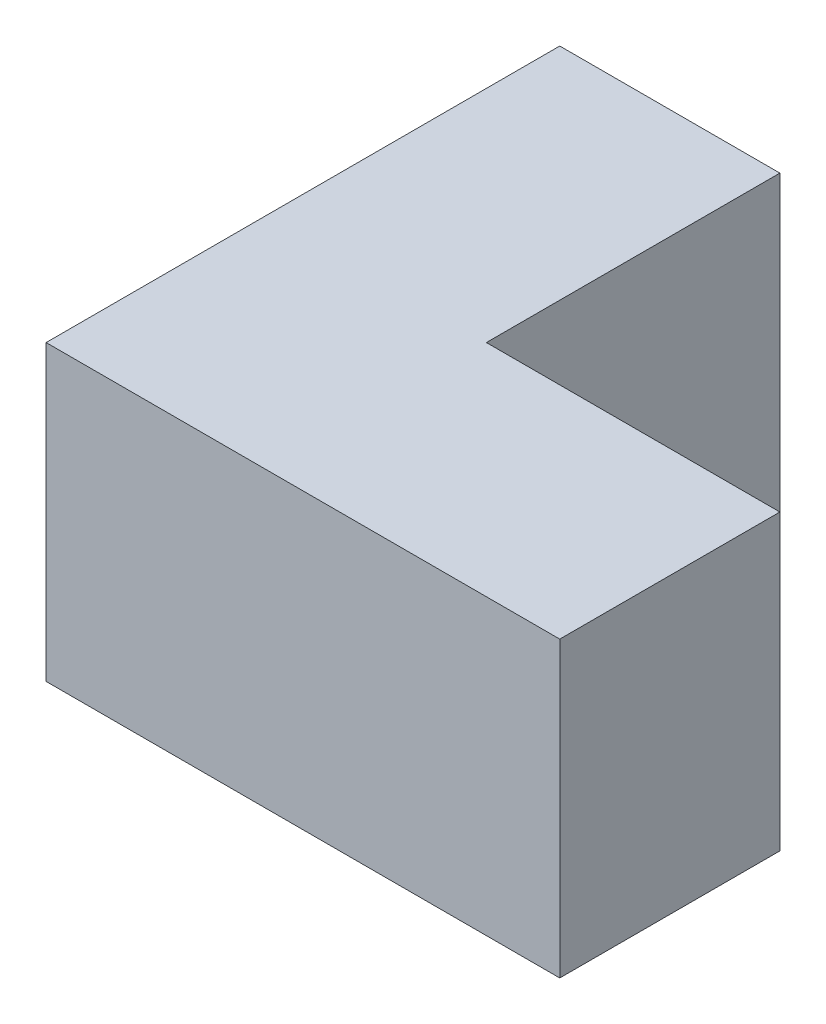
from build123d import *

# Parameters (mm, degrees)
SALIENTE_EXTRUIR1_DEPTH = 10


with BuildPart() as part:
    # Croquis1 → Saliente-Extruir1 (new body, symmetric)
    with BuildSketch(Plane(origin=(0, 0, 0), x_dir=(1, 0, 0), z_dir=(0, 1, 0))):
        Polygon((0, 0), (0, 20), (-15, 20), (-15, -15), (20, -15), (20, 0), align=None)
    extrude(amount=SALIENTE_EXTRUIR1_DEPTH, both=True)


solid = part.part
